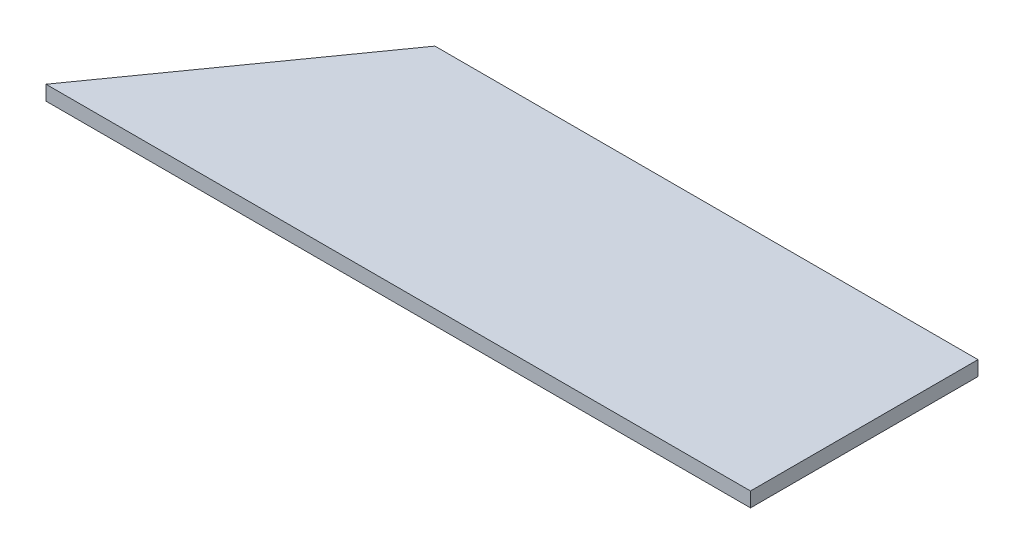
from build123d import *

# Parameters (mm, degrees)
BOSS_EXTRUDE1_DEPTH = 6.35


with BuildPart() as part:
    # Sketch1 → Boss-Extrude1 (new body)
    with BuildSketch(Plane(origin=(0, 0, 0), x_dir=(1, 0, 0), z_dir=(0, 1, 0))):
        Polygon((0, 0), (304.8, 0), (304.8, 98.425), (69.85, 98.425), align=None)
    extrude(amount=BOSS_EXTRUDE1_DEPTH)


solid = part.part
